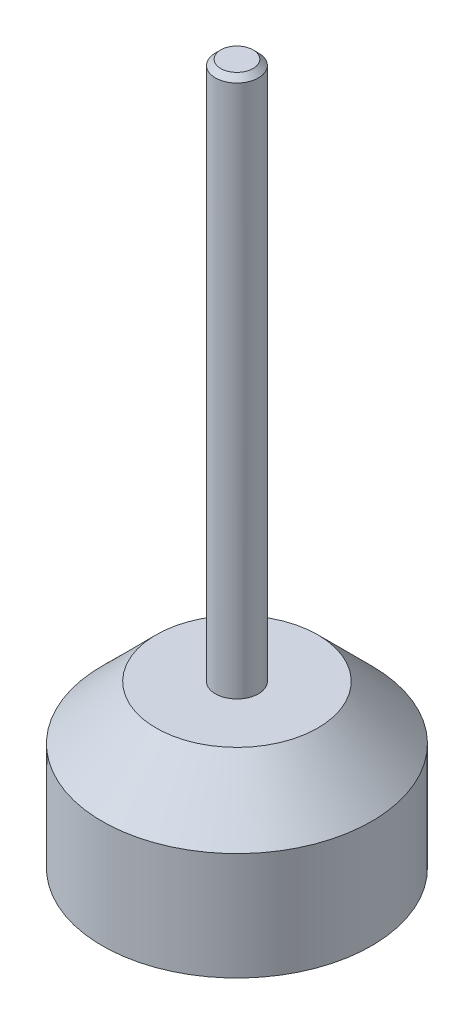
from build123d import *

# Parameters (mm, degrees)
CHAMFER_1_SIZE = 1


with BuildPart() as part:
    # Эскиз1 → Повернуть1 (revolve)
    with BuildSketch(Plane.XY):
        Polygon((0, 0), (25, 0), (25, 20), (15, 30), (4, 30), (4, 130), (0, 130), align=None)
    revolve(axis=Axis((0, 0, 0), (0, 1, 0)))

    # Фаска1
    chamfer_1_edges = [part.edges().sort_by_distance(p)[0] for p in [
        (-4, 130, 0),
    ]]
    chamfer(chamfer_1_edges, length=CHAMFER_1_SIZE)


solid = part.part
